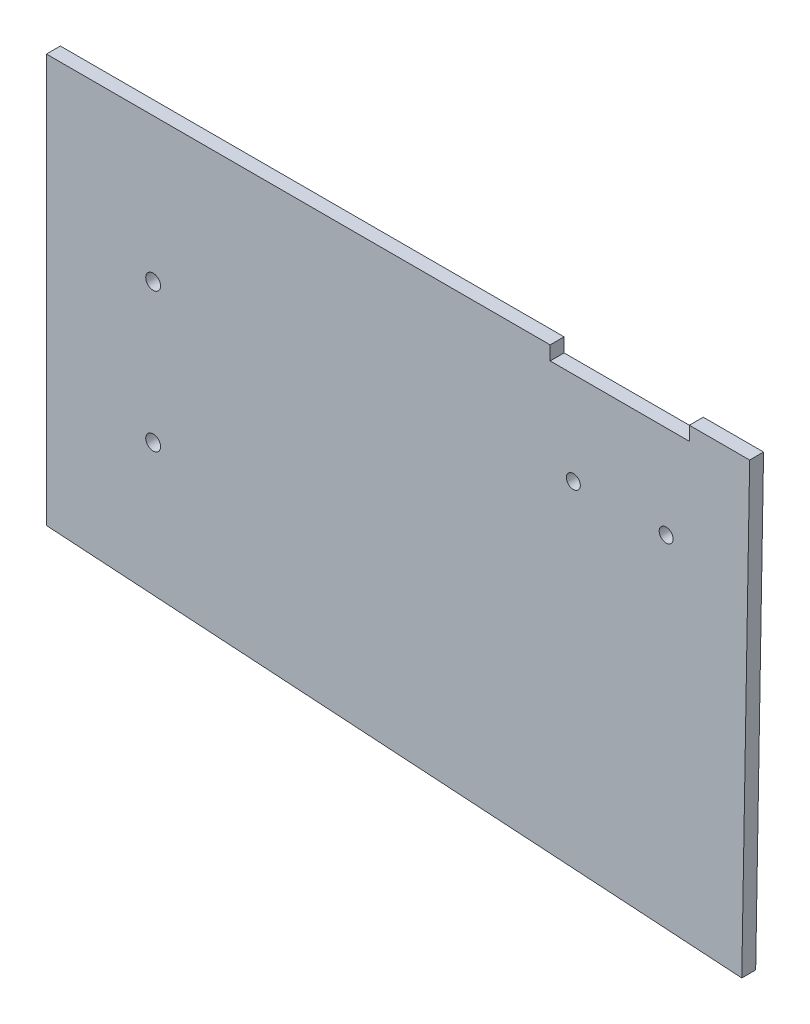
from build123d import *

# Parameters (mm, degrees)
BOSS_EXTRUDE1_DEPTH = 3
SKETCH2_W           = 30
SKETCH2_H           = 3
SKETCH2_R           = 1.5
CUT_EXTRUDE1_DEPTH  = 3
SKETCH3_R           = 1.6
CUT_EXTRUDE2_DEPTH  = 3


with BuildPart() as part:
    # Sketch1 → Boss-Extrude1 (new body)
    with BuildSketch(Plane.XY):
        Polygon((-33.355339059, 3), (118.208152802, 3), (116.505826096, -94.526231635), (-33.355339059, -85), align=None)
    extrude(amount=BOSS_EXTRUDE1_DEPTH)

    # Sketch2 → Cut-Extrude1 (cut)
    with BuildSketch(Plane.XY.offset(3)):
        with Locations((90.208152802, 1.5)):
            Rectangle(SKETCH2_W, SKETCH2_H)
        with Locations((80.208152802, -20)):
            Circle(SKETCH2_R)
        with Locations((100.208152802, -20)):
            Circle(SKETCH2_R)
    extrude(amount=-CUT_EXTRUDE1_DEPTH, mode=Mode.SUBTRACT)

    # Sketch3 → Cut-Extrude2 (cut)
    with BuildSketch(Plane(origin=(0, 0, 0), x_dir=(-1, 0, 0), z_dir=(0, 0, -1))):
        with Locations((10.355339059, -28)):
            Circle(SKETCH3_R)
        with Locations((10.355339059, -58)):
            Circle(SKETCH3_R)
    extrude(amount=-CUT_EXTRUDE2_DEPTH, mode=Mode.SUBTRACT)


solid = part.part
